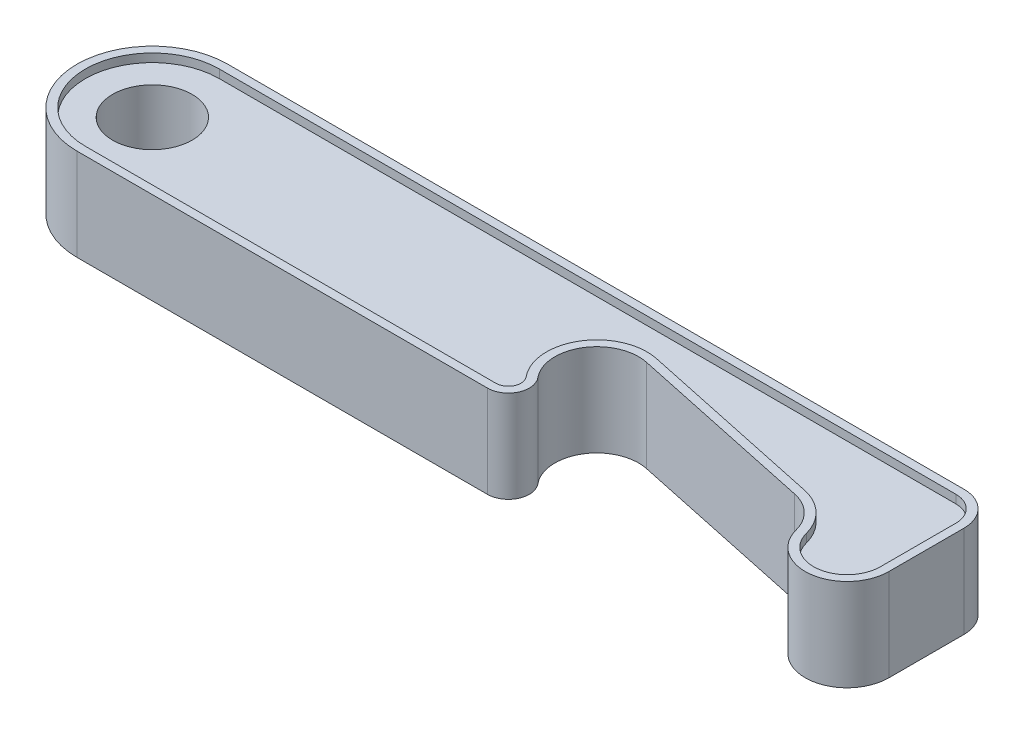
from build123d import *

# Parameters (mm, degrees)
BOSS_EXTRUDE6_DEPTH = 5.5
SKETCH1_6_R         = 4.75
BOSS_EXTRUDE7_DEPTH = 4.5


with BuildPart() as part:
    # Sketch1 → Boss-Extrude6 (new, symmetric)
    with BuildSketch(Plane(origin=(0, 0, 0), x_dir=(1, 0, 0), z_dir=(0, 1, 0))):
        with BuildLine():
            Line((87.999691057, 9), (0, 9))
            ThreePointArc((0, 9), (-9, 0), (0, -9))
            Line((0, -9), (49.039908292, -9))
            ThreePointArc((49.039908292, -9), (51.302145628, -7.564087513), (50.965683092, -4.905825787))
            ThreePointArc((50.965683092, -4.905825787), (50.53999843, 0.871975682), (55.856791146, 3.173260641))
            Line((55.856791146, 3.173260641), (78.356791146, -1.609261996))
            ThreePointArc((78.356791146, -1.609261996), (80.775506699, -2.888858783), (82.158461874, -5.25))
            ThreePointArc((82.158461874, -5.25), (87.629712519, -8.960148481), (91.999691057, -4))
            Line((91.999691057, -4), (91.999691057, 5))
            ThreePointArc((91.999691057, 5), (90.828118182, 7.828427125), (87.999691057, 9))
        make_face()
        with BuildLine():
            ThreePointArc((0, -8), (-8, 0), (0, 8))
            Line((0, 8), (87.999691057, 8))
            ThreePointArc((87.999691057, 8), (90.121011401, 7.121320344), (90.999691057, 5))
            Line((90.999691057, 5), (90.999691057, -4))
            ThreePointArc((90.999691057, -4), (87.503708227, -7.968118785), (83.126707711, -5))
            ThreePointArc((83.126707711, -5), (81.4671615, -2.166630539), (78.564702836, -0.631114396))
            Line((78.564702836, -0.631114396), (56.064702836, 4.151408242))
            ThreePointArc((56.064702836, 4.151408242), (49.684551577, 1.389866291), (50.195373172, -5.543495472))
            ThreePointArc((50.195373172, -5.543495472), (50.397250693, -7.138452508), (49.039908292, -8))
            Line((49.039908292, -8), (0, -8))
        make_face(mode=Mode.SUBTRACT)
    extrude(amount=BOSS_EXTRUDE6_DEPTH, both=True)

    # Sketch1_6 → Boss-Extrude7 (add, symmetric)
    with BuildSketch(Plane(origin=(0, 0, 0), x_dir=(1, 0, 0), z_dir=(0, 1, 0))):
        with BuildLine():
            Line((87.999691057, 8), (0, 8))
            ThreePointArc((0, 8), (-8, 0), (0, -8))
            Line((0, -8), (49.039908292, -8))
            ThreePointArc((49.039908292, -8), (50.397250693, -7.138452508), (50.195373172, -5.543495472))
            ThreePointArc((50.195373172, -5.543495472), (49.684551577, 1.389866291), (56.064702836, 4.151408242))
            Line((56.064702836, 4.151408242), (78.564702836, -0.631114396))
            ThreePointArc((78.564702836, -0.631114396), (81.4671615, -2.166630539), (83.126707711, -5))
            ThreePointArc((83.126707711, -5), (87.503708227, -7.968118785), (90.999691057, -4))
            Line((90.999691057, -4), (90.999691057, 5))
            ThreePointArc((90.999691057, 5), (90.121011401, 7.121320344), (87.999691057, 8))
        make_face()
        Circle(SKETCH1_6_R, mode=Mode.SUBTRACT)
    extrude(amount=BOSS_EXTRUDE7_DEPTH, both=True)


solid = part.part
